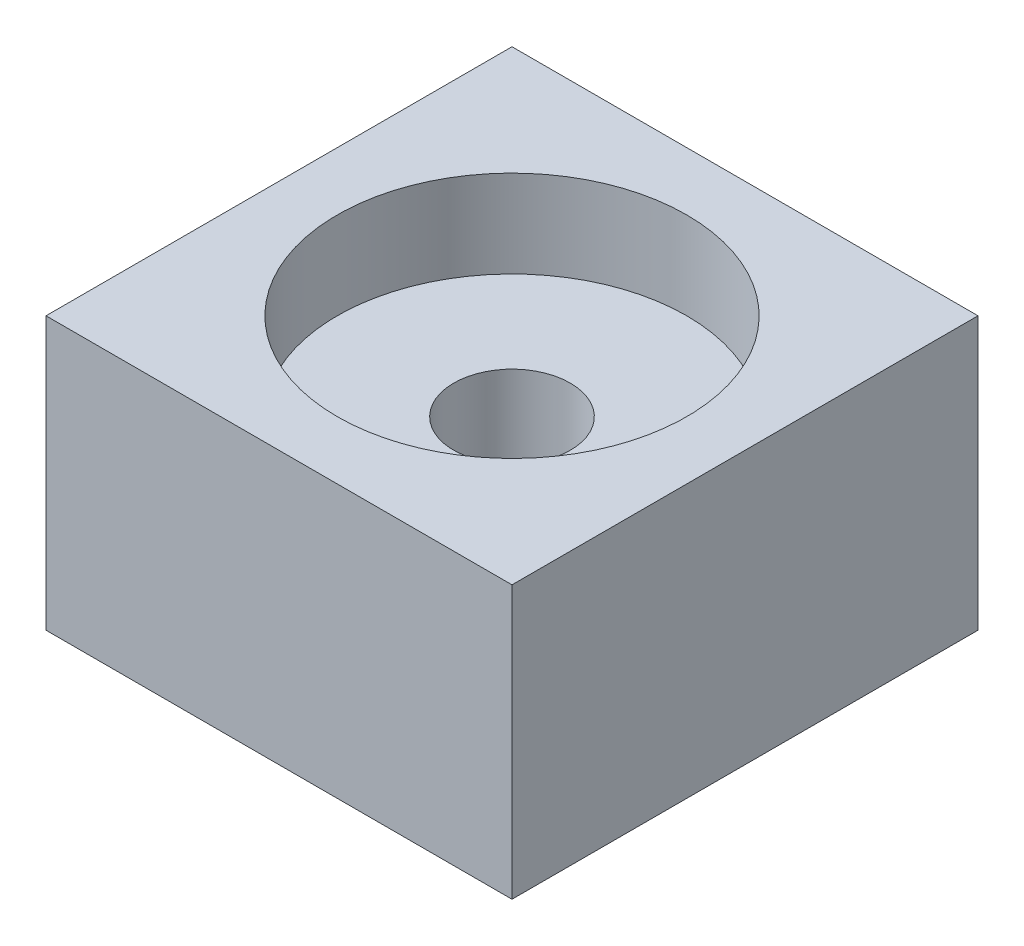
from build123d import *

# Parameters (mm, degrees)
SKETCH1_W           = 16
SKETCH1_H           = 16
SKETCH1_R           = 6
BOSS_EXTRUDE1_DEPTH = 3
SKETCH2_W           = 16
SKETCH2_H           = 16
BOSS_EXTRUDE2_DEPTH = 6.35
SKETCH3_R           = 2
CUT_EXTRUDE1_DEPTH  = 6.35


with BuildPart() as part:
    # Sketch1 → Boss-Extrude1 (new body)
    with BuildSketch(Plane(origin=(0, 0, 0), x_dir=(1, 0, 0), z_dir=(0, 1, 0))):
        with Locations((8, 8)):
            Rectangle(SKETCH1_W, SKETCH1_H)
        with Locations((8, 8)):
            Circle(SKETCH1_R, mode=Mode.SUBTRACT)
    extrude(amount=BOSS_EXTRUDE1_DEPTH)

    # Sketch2 → Boss-Extrude2 (add)
    with BuildSketch(Plane.XZ):
        with Locations((8, -8)):
            Rectangle(SKETCH2_W, SKETCH2_H)
    extrude(amount=BOSS_EXTRUDE2_DEPTH)

    # Sketch3 → Cut-Extrude1 (cut)
    with BuildSketch(Plane.XZ.offset(6.35)):
        with Locations((8, -8)):
            Circle(SKETCH3_R)
    extrude(amount=-CUT_EXTRUDE1_DEPTH, mode=Mode.SUBTRACT)


solid = part.part
